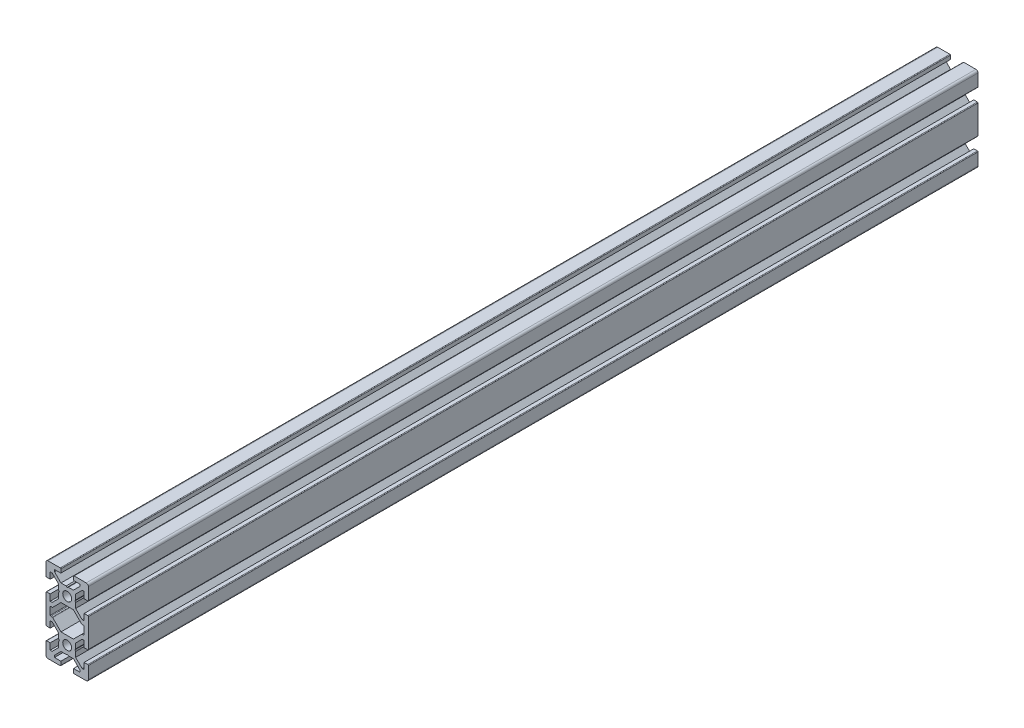
from build123d import *

# Parameters (mm, degrees)
SKETCH1_R           = 2.0999999
BOSS_EXTRUDE1_DEPTH = 420


with BuildPart() as part:
    # Sketch1 → Boss-Extrude1 (new body)
    with BuildSketch(Plane.XY):
        with BuildLine():
            Line((-10, -13.3000005), (-10, -19))
            ThreePointArc((-10, -19), (-9.707106781, -19.707106781), (-9, -20))
            Line((-9, -20), (-3.3, -20))
            ThreePointArc((-3.3, -20), (-3.087867966, -19.912132034), (-3, -19.7))
            Line((-3, -19.7), (-3, -18))
            Line((-3, -18), (-6, -18))
            Line((-6, -18), (-6, -17.0606825))
            Line((-6, -17.0606825), (-2.939318, -14))
            Line((-2.939318, -14), (-0.519615242, -14))
            Line((-0.519615242, -14), (0, -13.7))
            Line((0, -13.7), (0.519615242, -14))
            Line((0.519615242, -14), (2.9393365, -14))
            Line((2.9393365, -14), (6, -17.0606628))
            Line((6, -17.0606628), (6, -18))
            Line((6, -18), (3, -18))
            Line((3, -18), (3, -19.7))
            ThreePointArc((3, -19.7), (3.087867966, -19.912132034), (3.3, -20))
            Line((3.3, -20), (9, -20))
            ThreePointArc((9, -20), (9.707106781, -19.707106781), (10, -19))
            Line((10, -19), (10, -13.3000005))
            ThreePointArc((10, -13.3000005), (9.912132034, -13.087868466), (9.7, -13.0000005))
            Line((9.7, -13.0000005), (8, -13.0000005))
            Line((8, -13.0000005), (8, -16.0000005))
            Line((8, -16.0000005), (7.06065685, -16.0000005))
            Line((7.06065685, -16.0000005), (4, -12.93934215))
            Line((4, -12.93934215), (4, -10.519615742))
            Line((4, -10.519615742), (3.7, -10.0000005))
            Line((3.7, -10.0000005), (4, -9.480385258))
            Line((4, -9.480385258), (4, -7.06068365))
            Line((4, -7.06068365), (7.06068236, -4.000000504))
            Line((7.06068236, -4.000000504), (8, -4.000000504))
            Line((8, -4.000000504), (8, -7.0000005))
            Line((8, -7.0000005), (9.7, -7.0000005))
            ThreePointArc((9.7, -7.0000005), (9.912132034, -6.912132534), (10, -6.7000005))
            Line((10, -6.7000005), (10, 6.7))
            ThreePointArc((10, 6.7), (9.912132034, 6.912132034), (9.7, 7))
            Line((9.7, 7), (8, 7))
            Line((8, 7), (8, 4))
            Line((8, 4), (7.060678, 4))
            Line((7.060678, 4), (4, 7.06068075))
            Line((4, 7.06068075), (4, 9.480384758))
            Line((4, 9.480384758), (3.7, 10))
            Line((3.7, 10), (4, 10.519615242))
            Line((4, 10.519615242), (4, 12.93933675))
            Line((4, 12.93933675), (7.060661, 16))
            Line((7.060661, 16), (8, 16))
            Line((8, 16), (8, 13))
            Line((8, 13), (9.7, 13))
            ThreePointArc((9.7, 13), (9.912132034, 13.087867966), (10, 13.3))
            Line((10, 13.3), (10, 19))
            ThreePointArc((10, 19), (9.707106781, 19.707106781), (9, 20))
            Line((9, 20), (3.3, 20))
            ThreePointArc((3.3, 20), (3.087867966, 19.912132034), (3, 19.7))
            Line((3, 19.7), (3, 18))
            Line((3, 18), (6, 18))
            Line((6, 18), (6, 17.06065975))
            Line((6, 17.06065975), (2.939354, 14))
            Line((2.939354, 14), (0.519638625, 14))
            Line((0.519638625, 14), (0, 13.6999865))
            Line((0, 13.6999865), (-0.519638625, 14))
            Line((-0.519638625, 14), (-2.939335, 14))
            Line((-2.939335, 14), (-6, 17.060678))
            Line((-6, 17.060678), (-6, 18))
            Line((-6, 18), (-3, 18))
            Line((-3, 18), (-3, 19.7))
            ThreePointArc((-3, 19.7), (-3.087867966, 19.912132034), (-3.3, 20))
            Line((-3.3, 20), (-9, 20))
            ThreePointArc((-9, 20), (-9.707106781, 19.707106781), (-10, 19))
            Line((-10, 19), (-10, 13.3))
            ThreePointArc((-10, 13.3), (-9.912132034, 13.087867966), (-9.7, 13))
            Line((-9.7, 13), (-8, 13))
            Line((-8, 13), (-8, 16))
            Line((-8, 16), (-7.060642, 16))
            Line((-7.060642, 16), (-4, 12.9393565))
            Line((-4, 12.9393565), (-4, 10.519615242))
            Line((-4, 10.519615242), (-3.7, 10))
            Line((-3.7, 10), (-4, 9.480384758))
            Line((-4, 9.480384758), (-4, 7.06066))
            Line((-4, 7.06066), (-7.060659, 4))
            Line((-7.060659, 4), (-8, 4))
            Line((-8, 4), (-8, 7))
            Line((-8, 7), (-9.7, 7))
            ThreePointArc((-9.7, 7), (-9.912132034, 6.912132034), (-10, 6.7))
            Line((-10, 6.7), (-10, -6.7000005))
            ThreePointArc((-10, -6.7000005), (-9.912132034, -6.912132534), (-9.7, -7.0000005))
            Line((-9.7, -7.0000005), (-8, -7.0000005))
            Line((-8, -7.0000005), (-8, -4.0000005))
            Line((-8, -4.0000005), (-7.06066257, -4.0000005))
            Line((-7.06066257, -4.0000005), (-4, -7.0606688))
            Line((-4, -7.0606688), (-4, -9.480385258))
            Line((-4, -9.480385258), (-3.7, -10.0000005))
            Line((-3.7, -10.0000005), (-4, -10.519615742))
            Line((-4, -10.519615742), (-4, -12.9393575))
            Line((-4, -12.9393575), (-7.0606365, -16.0000005))
            Line((-7.0606365, -16.0000005), (-8, -16.0000005))
            Line((-8, -16.0000005), (-8, -13.0000005))
            Line((-8, -13.0000005), (-9.7, -13.0000005))
            ThreePointArc((-9.7, -13.0000005), (-9.912132034, -13.087868466), (-10, -13.3000005))
        make_face()
        with Locations((0, 10)):
            Circle(SKETCH1_R, mode=Mode.SUBTRACT)
        with Locations((0, -10.0000005)):
            Circle(SKETCH1_R, mode=Mode.SUBTRACT)
        with BuildLine():
            Line((-8, 1.6999995), (-8, -1.70000025))
            ThreePointArc((-8, -1.70000025), (-7.912132034, -1.912132284), (-7.7, -2.00000025))
            Line((-7.7, -2.00000025), (-7.063604538, -2.00000025))
            ThreePointArc((-7.063604538, -2.00000025), (-6.948800316, -2.022823986), (-6.851481305, -2.087861995))
            Line((-6.851481305, -2.087861995), (-2.939335, -6))
            Line((-2.939335, -6), (2.93933195, -6))
            Line((2.93933195, -6), (6.851479294, -2.087861656))
            ThreePointArc((6.851479294, -2.087861656), (6.948799922, -2.022824212), (7.06360515, -2.00000025))
            Line((7.06360515, -2.00000025), (7.7, -2.00000025))
            ThreePointArc((7.7, -2.00000025), (7.912132034, -1.912132284), (8, -1.70000025))
            Line((8, -1.70000025), (8, 1.6999995))
            ThreePointArc((8, 1.6999995), (7.912132034, 1.912131534), (7.7, 1.9999995))
            Line((7.7, 1.9999995), (7.06359945, 1.9999995))
            ThreePointArc((7.06359945, 1.9999995), (6.9487942, 2.022823721), (6.851474147, 2.087862153))
            Line((6.851474147, 2.087862153), (2.9393355, 6))
            Line((2.9393355, 6), (-2.939339, 6))
            Line((-2.939339, 6), (-6.851476944, 2.087862556))
            ThreePointArc((-6.851476944, 2.087862556), (-6.948795311, 2.022823488), (-7.063599538, 1.9999995))
            Line((-7.063599538, 1.9999995), (-7.7, 1.9999995))
            ThreePointArc((-7.7, 1.9999995), (-7.912132034, 1.912131534), (-8, 1.6999995))
        make_face(mode=Mode.SUBTRACT)
    extrude(amount=-BOSS_EXTRUDE1_DEPTH)


solid = part.part
